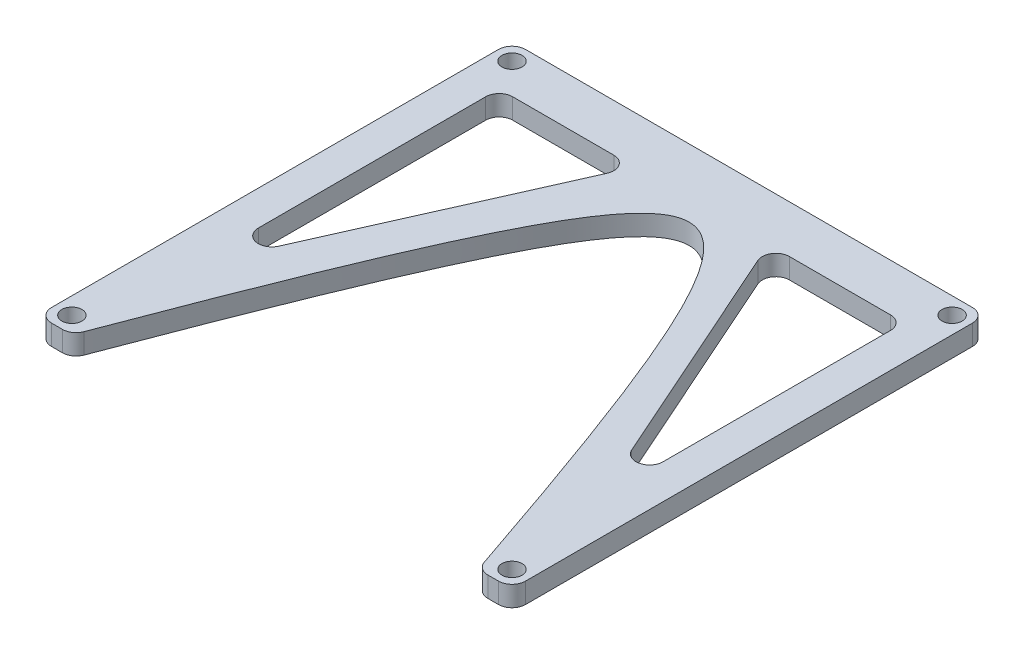
from build123d import *

# Parameters (mm, degrees)
BOSS_EXTRUDE1_DEPTH = 3
SKETCH3_R           = 1.488133846
CUT_EXTRUDE1_DEPTH  = 50.58830522
FILLET1_R           = 2
CUT_EXTRUDE2_DEPTH  = 50.58830522
FILLET2_R           = 2


with BuildPart() as part:
    # Sketch2 → Boss-Extrude1 (new body)
    with BuildSketch(Plane(origin=(0, 0, 0), x_dir=(1, 0, 0), z_dir=(0, 1, 0))):
        with BuildLine():
            Line((-30, -35), (-35, -35))
            Line((-35, -35), (-35, 35))
            Line((-35, 35), (35, 35))
            Line((35, 35), (35, -35))
            Line((35, -35), (30, -35))
            add(Edge.make_bspline(
                [(-30, -35), (1.605503948, 49.102253739), (30, -35)],
                knots=[0, 0, 0, 1, 1, 1], degree=2, weights=[1, 2.489393758, 1]))
        make_face()
    extrude(amount=BOSS_EXTRUDE1_DEPTH)

    # Sketch3 → Cut-Extrude1 (cut, through all)
    with BuildSketch(Plane(origin=(0, 3, 0), x_dir=(1, 0, 0), z_dir=(0, 1, 0))):
        with Locations(Location((-32.5, 32.5, 0), (0, 0, 270))):
            Circle(SKETCH3_R)
        with Locations(Location((32.5, 32.5, 0), (0, 0, 270))):
            Circle(SKETCH3_R)
        with Locations(Location((32.5, -32.5, 0), (0, 0, 270))):
            Circle(SKETCH3_R)
        with Locations(Location((-32.5, -32.5, 0), (0, 0, 270))):
            Circle(SKETCH3_R)
    extrude(amount=-CUT_EXTRUDE1_DEPTH, mode=Mode.SUBTRACT)

    # Fillet1
    fillet1_edges = [part.edges().sort_by_distance(p)[0] for p in [
        (35, 1.5, 35),
        (30, 1.5, 35),
        (-30, 1.5, 35),
        (-35, 1.5, 35),
        (-35, 1.5, -35),
        (35, 1.5, -35),
    ]]
    fillet(fillet1_edges, radius=FILLET1_R)

    # Sketch4 → Cut-Extrude2 (cut, through all)
    with BuildSketch(Plane(origin=(0, 3, 0), x_dir=(1, 0, 0), z_dir=(0, 1, 0))):
        Polygon((-29.891619327, -17), (-29.891619327, 28), (-9.891619327, 28), align=None)
        Polygon((29.891619327, -17), (29.891619327, 28), (9.891619327, 28), align=None)
    extrude(amount=-CUT_EXTRUDE2_DEPTH, mode=Mode.SUBTRACT)

    # Fillet2
    fillet2_edges = [part.edges().sort_by_distance(p)[0] for p in [
        (-9.891619327, 1.5, -28),
        (-29.891619327, 1.5, 17),
        (-29.891619327, 1.5, -28),
        (29.891619327, 1.5, 17),
        (9.891619327, 1.5, -28),
        (29.891619327, 1.5, -28),
    ]]
    fillet(fillet2_edges, radius=FILLET2_R)


solid = part.part
